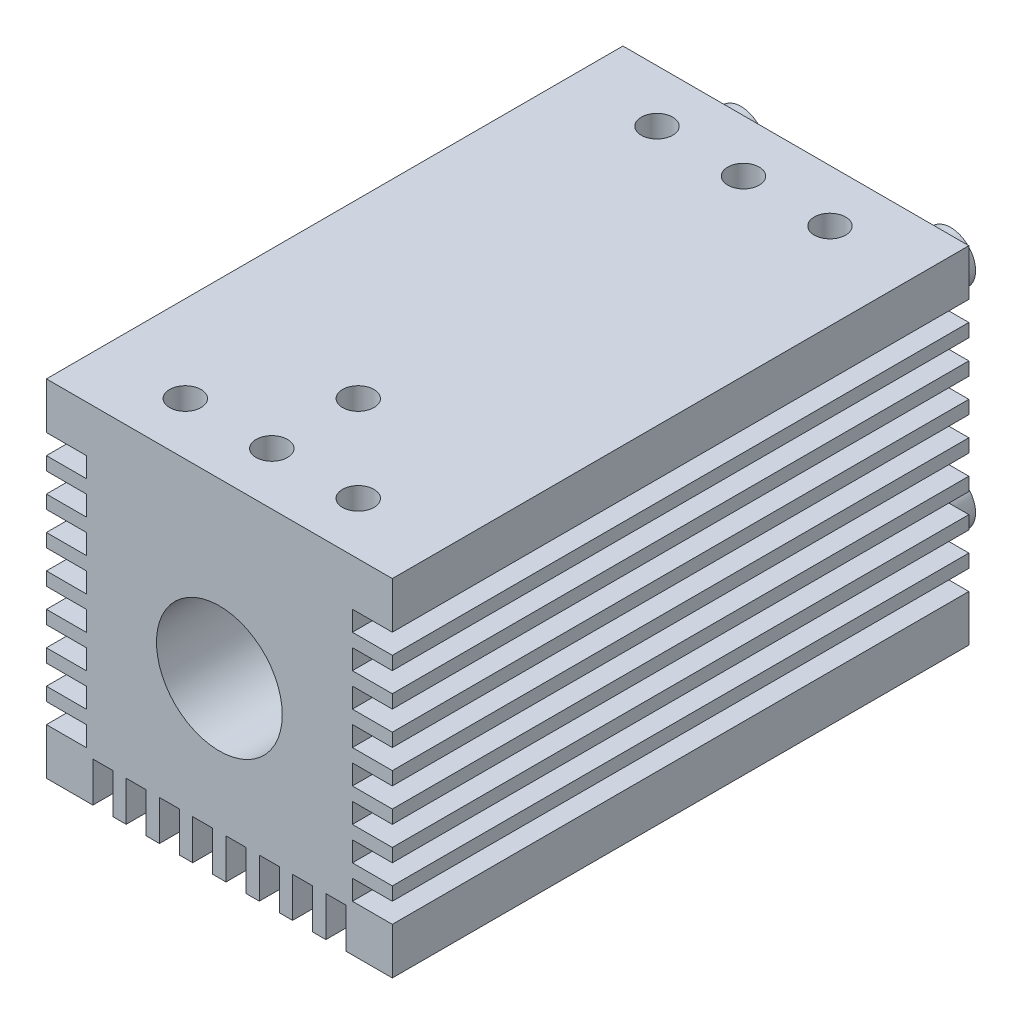
from build123d import *

# Parameters (mm, degrees)
SKETCH1_W           = 33
SKETCH1_H           = 33
SKETCH1_R           = 6
BOSS_EXTRUDE1_DEPTH = 55
SKETCH2_R           = 1.5
CUT_EXTRUDE1_DEPTH  = 12.7
SKETCH5_W           = 3.81
SKETCH5_H           = 1.905
SKETCH5_W_2         = 1.905
SKETCH5_H_2         = 3.81
CUT_EXTRUDE2_DEPTH  = 73.131823889
SKETCH3_R           = 2.38125
BOSS_EXTRUDE2_DEPTH = 4.7625


with BuildPart() as part:
    # Sketch1 → Boss-Extrude1 (new body)
    with BuildSketch(Plane.XY):
        with Locations((16.5, 16.5)):
            Rectangle(SKETCH1_W, SKETCH1_H)
        with Locations((16.5, 16.5)):
            Circle(SKETCH1_R, mode=Mode.SUBTRACT)
    extrude(amount=-BOSS_EXTRUDE1_DEPTH)

    # Sketch2 → Cut-Extrude1 (cut)
    with BuildSketch(Plane(origin=(0, 33, 0), x_dir=(1, 0, 0), z_dir=(0, 1, 0))):
        with Locations((8.25, 5)):
            Circle(SKETCH2_R)
        with Locations((16.5, 5)):
            Circle(SKETCH2_R)
        with Locations((24.75, 5)):
            Circle(SKETCH2_R)
        with Locations((8.25, 50)):
            Circle(SKETCH2_R)
        with Locations((16.5, 50)):
            Circle(SKETCH2_R)
        with Locations((24.75, 50)):
            Circle(SKETCH2_R)
        with Locations((16.5, 13.25)):
            Circle(SKETCH2_R)
    extrude(amount=-CUT_EXTRUDE1_DEPTH, mode=Mode.SUBTRACT)

    # Sketch5 → Cut-Extrude2 (cut, through all)
    with BuildSketch(Plane.XY):
        with Locations((1.905, 5.3875)):
            Rectangle(SKETCH5_W, SKETCH5_H)
        with Locations((1.905, 27.6125)):
            Rectangle(SKETCH5_W, SKETCH5_H)
        with Locations((1.905, 24.4375)):
            Rectangle(SKETCH5_W, SKETCH5_H)
        with Locations((1.905, 21.2625)):
            Rectangle(SKETCH5_W, SKETCH5_H)
        with Locations((1.905, 18.0875)):
            Rectangle(SKETCH5_W, SKETCH5_H)
        with Locations((1.905, 14.9125)):
            Rectangle(SKETCH5_W, SKETCH5_H)
        with Locations((1.905, 11.7375)):
            Rectangle(SKETCH5_W, SKETCH5_H)
        with Locations((1.905, 8.5625)):
            Rectangle(SKETCH5_W, SKETCH5_H)
        with Locations((31.095, 27.6125)):
            Rectangle(SKETCH5_W, SKETCH5_H)
        with Locations((31.095, 24.4375)):
            Rectangle(SKETCH5_W, SKETCH5_H)
        with Locations((31.095, 21.2625)):
            Rectangle(SKETCH5_W, SKETCH5_H)
        with Locations((31.095, 18.0875)):
            Rectangle(SKETCH5_W, SKETCH5_H)
        with Locations((31.095, 14.9125)):
            Rectangle(SKETCH5_W, SKETCH5_H)
        with Locations((31.095, 11.7375)):
            Rectangle(SKETCH5_W, SKETCH5_H)
        with Locations((31.095, 8.5625)):
            Rectangle(SKETCH5_W, SKETCH5_H)
        with Locations((31.095, 5.3875)):
            Rectangle(SKETCH5_W, SKETCH5_H)
        with Locations((27.6125, 1.905)):
            Rectangle(SKETCH5_W_2, SKETCH5_H_2)
        with Locations((24.4375, 1.905)):
            Rectangle(SKETCH5_W_2, SKETCH5_H_2)
        with Locations((21.2625, 1.905)):
            Rectangle(SKETCH5_W_2, SKETCH5_H_2)
        with Locations((18.0875, 1.905)):
            Rectangle(SKETCH5_W_2, SKETCH5_H_2)
        with Locations((14.9125, 1.905)):
            Rectangle(SKETCH5_W_2, SKETCH5_H_2)
        with Locations((11.7375, 1.905)):
            Rectangle(SKETCH5_W_2, SKETCH5_H_2)
        with Locations((8.5625, 1.905)):
            Rectangle(SKETCH5_W_2, SKETCH5_H_2)
        with Locations((5.3875, 1.905)):
            Rectangle(SKETCH5_W_2, SKETCH5_H_2)
    extrude(amount=-CUT_EXTRUDE2_DEPTH, mode=Mode.SUBTRACT)

    # Sketch3 → Boss-Extrude2 (add)
    with BuildSketch(Plane.XY.offset(-55)):
        with Locations((6.5, 26.5)):
            Circle(SKETCH3_R)
        with Locations((26.5, 26.5)):
            Circle(SKETCH3_R)
        with Locations((26.5, 6.5)):
            Circle(SKETCH3_R)
        with Locations((6.5, 6.5)):
            Circle(SKETCH3_R)
    extrude(amount=-BOSS_EXTRUDE2_DEPTH)


solid = part.part
